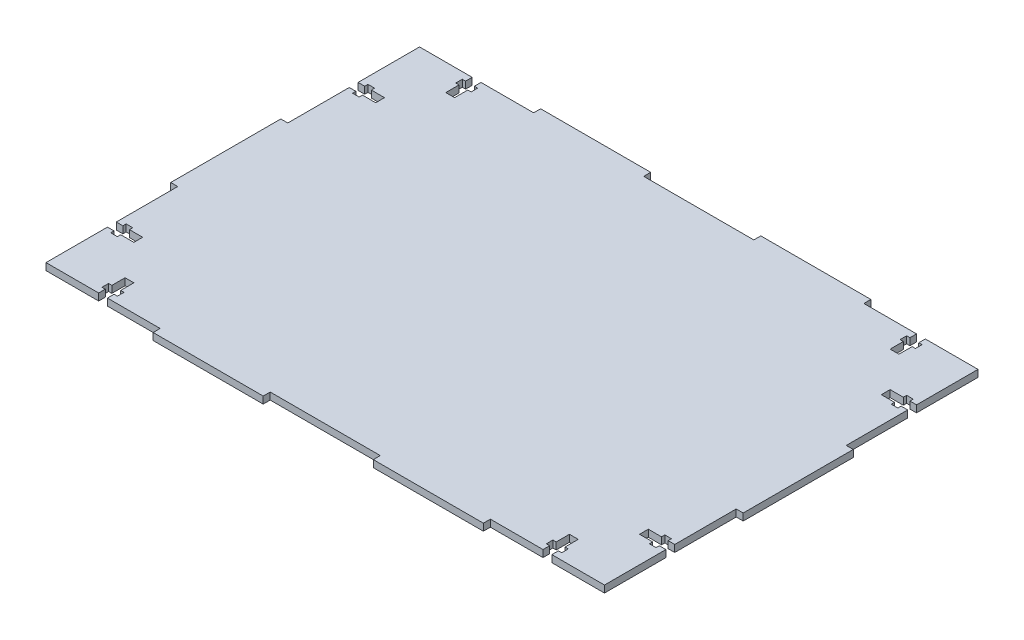
from build123d import *

# Parameters (mm, degrees)
BOSS_EXTRUDE1_DEPTH     = 1.5875
CUT_EXTRUDE1_DEPTH      = 1
CUT_EXTRUDE1_DEPTH_BACK = 4.175


with BuildPart() as part:
    # Sketch1 → Boss-Extrude1 (new body, symmetric)
    with BuildSketch(Plane(origin=(0, 0, 0), x_dir=(1, 0, 0), z_dir=(0, 1, 0))):
        Polygon((55, 3.175), (55, 0), (105, 0), (105, 3.175), (155, 3.175), (155, 0), (205, 0), (205, 3.175), (256.825, 3.175), (256.825, 63), (260, 63), (260, 113), (256.825, 113), (256.825, 172.825), (205, 172.825), (205, 176), (155, 176), (155, 172.825), (105, 172.825), (105, 176), (55, 176), (55, 172.825), (3.175, 172.825), (3.175, 113), (0, 113), (0, 63), (3.175, 63), (3.175, 3.175), align=None)
    extrude(amount=BOSS_EXTRUDE1_DEPTH, both=True)

    # Sketch3 → Cut-Extrude1 (cut, two sides)
    with BuildSketch(Plane(origin=(0, 1.5875, 0), x_dir=(1, 0, 0), z_dir=(0, 1, 0))) as cut_extrude1_sk:
        Polygon((228.9125, 3.175), (232.9125, 3.175), (232.9125, 6.175), (234.4125, 6.175), (234.4125, 9.175), (232.9125, 9.175), (232.9125, 15.175), (228.9125, 15.175), (228.9125, 9.175), (227.4125, 9.175), (227.4125, 6.175), (228.9125, 6.175), align=None)
        Polygon((253.825, 31.0875), (256.825, 31.0875), (256.825, 35.0875), (253.825, 35.0875), (253.825, 36.5875), (250.825, 36.5875), (250.825, 35.0875), (244.825, 35.0875), (244.825, 31.0875), (250.825, 31.0875), (250.825, 29.5875), (253.825, 29.5875), align=None)
        Polygon((253.825, 140.9125), (256.825, 140.9125), (256.825, 144.9125), (253.825, 144.9125), (253.825, 146.4125), (250.825, 146.4125), (250.825, 144.9125), (244.825, 144.9125), (244.825, 140.9125), (250.825, 140.9125), (250.825, 139.4125), (253.825, 139.4125), align=None)
        Polygon((232.9125, 169.825), (232.9125, 172.825), (228.9125, 172.825), (228.9125, 169.825), (227.4125, 169.825), (227.4125, 166.825), (228.9125, 166.825), (228.9125, 160.825), (232.9125, 160.825), (232.9125, 166.825), (234.4125, 166.825), (234.4125, 169.825), align=None)
        Polygon((25.5875, 169.825), (25.5875, 166.825), (27.0875, 166.825), (27.0875, 160.825), (31.0875, 160.825), (31.0875, 166.825), (32.5875, 166.825), (32.5875, 169.825), (31.0875, 169.825), (31.0875, 172.825), (27.0875, 172.825), (27.0875, 169.825), align=None)
        Polygon((6.175, 144.9125), (3.175, 144.9125), (3.175, 140.9125), (6.175, 140.9125), (6.175, 139.4125), (9.175, 139.4125), (9.175, 140.9125), (15.175, 140.9125), (15.175, 144.9125), (9.175, 144.9125), (9.175, 146.4125), (6.175, 146.4125), align=None)
        Polygon((6.175, 35.0875), (3.175, 35.0875), (3.175, 31.0875), (6.175, 31.0875), (6.175, 29.5875), (9.175, 29.5875), (9.175, 31.0875), (15.175, 31.0875), (15.175, 35.0875), (9.175, 35.0875), (9.175, 36.5875), (6.175, 36.5875), align=None)
        Polygon((27.0875, 6.175), (27.0875, 3.175), (31.0875, 3.175), (31.0875, 6.175), (32.5875, 6.175), (32.5875, 9.175), (31.0875, 9.175), (31.0875, 15.175), (27.0875, 15.175), (27.0875, 9.175), (25.5875, 9.175), (25.5875, 6.175), align=None)
    extrude(amount=CUT_EXTRUDE1_DEPTH, mode=Mode.SUBTRACT)
    extrude(cut_extrude1_sk.sketch, amount=-CUT_EXTRUDE1_DEPTH_BACK, mode=Mode.SUBTRACT)


solid = part.part
